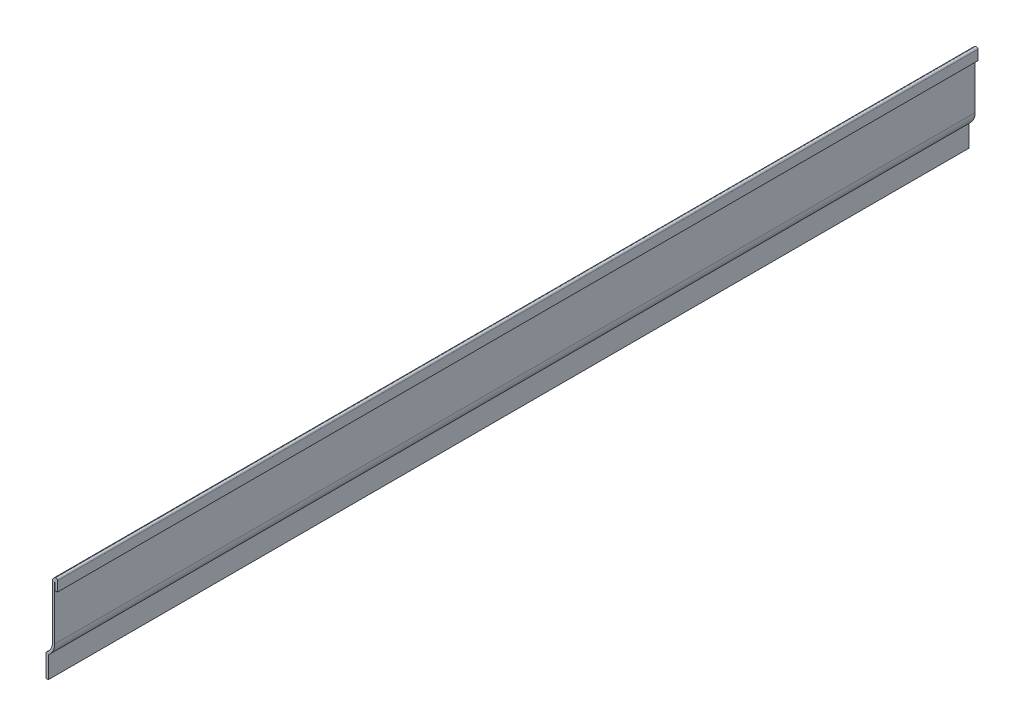
from build123d import *

# Parameters (mm, degrees)
EXTRUDE_THIN1_DEPTH = 508
FILLET1_R           = 1.27
FILLET2_R           = 0.889


with BuildPart() as part:
    # Sketch1 → Extrude-Thin1 (new body)
    with BuildSketch(Plane.XY):
        with BuildLine():
            Line((0, 44.45), (0, 50.8))
            ThreePointArc((0, 50.8), (-1.943679558, 50.278693106), (-2.794, 48.454794465))
            Line((-2.794, 48.454794465), (-2.794, 18.877476346))
            ThreePointArc((-2.794, 18.877476346), (-3.7465, 15.313547685), (-6.35, 12.7))
            Line((-6.35, 12.7), (-6.35, 0))
            Line((-6.35, 0), (-5.08, 0))
            Line((-5.08, 0), (-5.08, 12.007727151))
            ThreePointArc((-5.08, 12.007727151), (-2.465699307, 15.009705993), (-1.524, 18.877476346))
            Line((-1.524, 18.877476346), (-1.524, 48.454794465))
            ThreePointArc((-1.524, 48.454794465), (-1.458573987, 48.830465532), (-1.27, 49.161900539))
            Line((-1.27, 49.161900539), (-1.27, 44.45))
            Line((-1.27, 44.45), (0, 44.45))
        make_face()
    extrude(amount=-EXTRUDE_THIN1_DEPTH)

    # Fillet1
    fillet1_edges = [part.edges().sort_by_distance(p)[0] for p in [
        (-6.35, 12.7, -254),
    ]]
    fillet(fillet1_edges, radius=FILLET1_R)

    # Fillet2
    fillet2_edges = [part.edges().sort_by_distance(p)[0] for p in [
        (0, 50.8, -254),
    ]]
    fillet(fillet2_edges, radius=FILLET2_R)


solid = part.part
